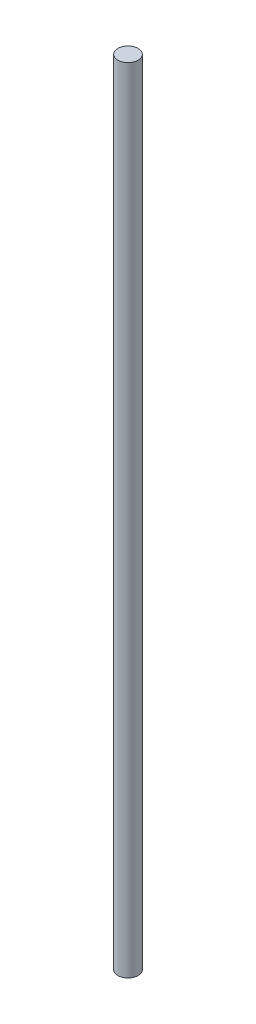
from build123d import *

# Parameters (mm, degrees)
SKETCH1_R           = 3.175
BOSS_EXTRUDE1_DEPTH = 247.65


with BuildPart() as part:
    # Sketch1 → Boss-Extrude1 (new body)
    with BuildSketch(Plane(origin=(0, 0, 0), x_dir=(1, 0, 0), z_dir=(0, 1, 0))):
        Circle(SKETCH1_R)
    extrude(amount=BOSS_EXTRUDE1_DEPTH)


solid = part.part
